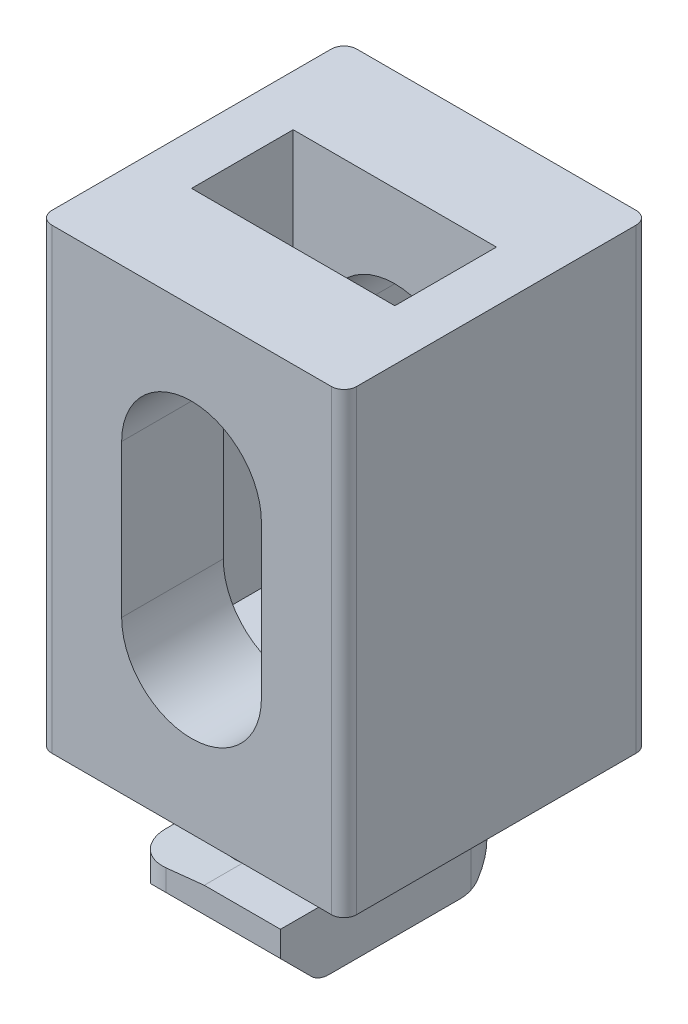
from build123d import *

# Parameters (mm, degrees)
SKETCH_1_W               = 12
SKETCH_1_H               = 18
EXTRUDE_1_DEPTH          = 12
CUT_EXTRUDE_1_DEPTH      = 12
SKETCH_3_W               = 8
SKETCH_3_H               = 4
CUT_EXTRUDE_2_DEPTH      = 15
EXTRUDE_2_DEPTH          = 4.5
SKETCH_5_W               = 6
SKETCH_5_H               = 9
EXTRUDE_3_DEPTH          = 2.5
FILLET_2_R               = 0.5
CHAMFER_3_SIZE           = 1.5
CHAMFER_4_SIZE           = 1.5
FILLET_3_R               = 1
CUT_EXTRUDE_3_REACH      = 13.5
CUT_EXTRUDE_3_END_RADIUS = 3
CUT_EXTRUDE_4_REACH      = 11.5
CUT_EXTRUDE_4_END_RADIUS = 3
FILLET_6_R               = 1.5
FILLET_7_R               = 1.5


with BuildPart() as part:
    # 草图1 → 拉伸1 (new body)
    with BuildSketch(Plane.XY):
        with Locations((6, 9)):
            Rectangle(SKETCH_1_W, SKETCH_1_H)
    extrude(amount=EXTRUDE_1_DEPTH)

    # 草图2 → 切除-拉伸1 (cut)
    with BuildSketch(Plane.XY.offset(12)):
        with BuildLine():
            Line((3.25, 12.000000088), (3.25, 5.999999721))
            ThreePointArc((3.25, 5.999999721), (6, 3.25), (8.75, 5.999999721))
            Line((8.75, 5.999999721), (8.75, 12.000000088))
            ThreePointArc((8.75, 12.000000088), (6, 14.75), (3.25, 12.000000088))
        make_face()
    extrude(amount=-CUT_EXTRUDE_1_DEPTH, mode=Mode.SUBTRACT)

    # 草图3 → 切除-拉伸2 (cut)
    with BuildSketch(Plane(origin=(0, 18, 0), x_dir=(1, 0, 0), z_dir=(0, 1, 0))):
        with Locations((6, -6)):
            Rectangle(SKETCH_3_W, SKETCH_3_H)
    extrude(amount=-CUT_EXTRUDE_2_DEPTH, mode=Mode.SUBTRACT)

    # 草图4 → 拉伸2 (add)
    with BuildSketch(Plane.XZ):
        with BuildLine():
            Line((9, 10), (6, 10))
            ThreePointArc((6, 10), (3.878679656, 9.121320344), (3, 7))
            Line((3, 7), (3, 4))
            Line((3, 4), (6, 4))
            ThreePointArc((6, 4), (8.121320344, 4.878679656), (9, 7))
            Line((9, 7), (9, 10))
        make_face()
    extrude(amount=EXTRUDE_2_DEPTH)

    # 草图5 → 拉伸3 (add)
    with BuildSketch(Plane.XZ.offset(4.5)):
        with Locations((6, 7)):
            Rectangle(SKETCH_5_W, SKETCH_5_H)
    extrude(amount=-EXTRUDE_3_DEPTH)

    # 圆角2
    fillet_2_edges = [part.edges().sort_by_distance(p)[0] for p in [
        (12, 9, 12),
        (0, 9, 12),
        (12, 9, 0),
        (0, 9, 0),
    ]]
    fillet(fillet_2_edges, radius=FILLET_2_R)

    # 倒角3
    chamfer_3_edges = [part.edges().sort_by_distance(p)[0] for p in [
        (6, -4.5, 11.5),
    ]]
    chamfer(chamfer_3_edges, length=CHAMFER_3_SIZE)

    # 倒角4
    chamfer_4_edges = [part.edges().sort_by_distance(p)[0] for p in [
        (6, -4.5, 2.5),
    ]]
    chamfer(chamfer_4_edges, length=CHAMFER_4_SIZE)

    # 圆角3
    fillet_3_edges = [part.edges().sort_by_distance(p)[0] for p in [
        (6, -4.5, 10),
        (6, -4.5, 4),
    ]]
    fillet(fillet_3_edges, radius=FILLET_3_R)

    # 切除-拉伸3: up to this cylinder (the profile starts outside it)
    cut_extrude_3_end = Plane(origin=(6, -2.105104, 7), z_dir=(0, 1, 0)) * Cylinder(CUT_EXTRUDE_3_END_RADIUS, 34, mode=Mode.PRIVATE)
    # 草图8 → 切除-拉伸3 (cut, up to the surface)
    with BuildSketch(Plane.XY.offset(11.5), mode=Mode.PRIVATE) as cut_extrude_3_sk1:
        Polygon((6, -2), (3, -2), (3, -2.315312706), align=None)
    cut_extrude_3_tool1 = extrude(cut_extrude_3_sk1.sketch, amount=-CUT_EXTRUDE_3_REACH, mode=Mode.PRIVATE) - cut_extrude_3_end
    add(cut_extrude_3_tool1.solids().sort_by_distance((4, -2.105104, 11.5))[0], mode=Mode.SUBTRACT)

    # 切除-拉伸4: up to this cylinder (the profile starts outside it)
    cut_extrude_4_end = Plane(origin=(6, -2.105104, 7), z_dir=(0, 1, 0)) * Cylinder(CUT_EXTRUDE_4_END_RADIUS, 30, mode=Mode.PRIVATE)
    # 草图9 → 切除-拉伸4 (cut, up to the surface)
    with BuildSketch(Plane(origin=(0, 0, 2.5), x_dir=(-1, 0, 0), z_dir=(0, 0, -1)), mode=Mode.PRIVATE) as cut_extrude_4_sk1:
        Polygon((-6, -2), (-9, -2), (-9, -2.315312706), align=None)
    cut_extrude_4_tool1 = extrude(cut_extrude_4_sk1.sketch, amount=-CUT_EXTRUDE_4_REACH, mode=Mode.PRIVATE) - cut_extrude_4_end
    add(cut_extrude_4_tool1.solids().sort_by_distance((8, -2.105104, 2.5))[0], mode=Mode.SUBTRACT)

    # 圆角6
    fillet_6_edges = [part.edges().sort_by_distance(p)[0] for p in [
        (9, -2.657656353, 2.5),
    ]]
    fillet(fillet_6_edges, radius=FILLET_6_R)

    # 圆角7
    fillet_7_edges = [part.edges().sort_by_distance(p)[0] for p in [
        (3, -2.657656353, 11.5),
    ]]
    fillet(fillet_7_edges, radius=FILLET_7_R)


solid = part.part
